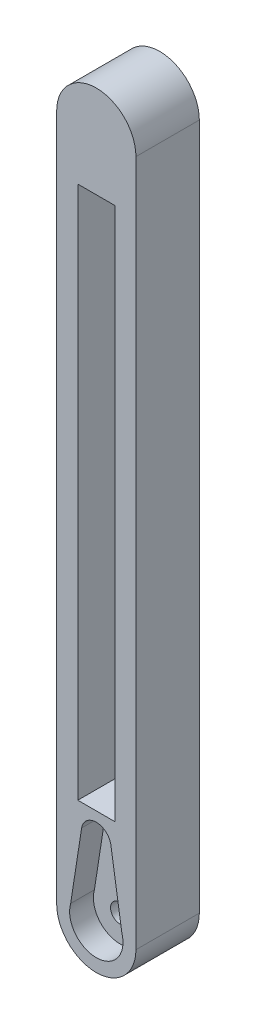
from build123d import *

# Parameters (mm, degrees)
BOSS_EXTRUDE1_DEPTH = 12
SKETCH5_W           = 7
SKETCH5_H           = 112.5
CUT_EXTRUDE3_DEPTH  = 12
SKETCH6_R           = 5.15
CUT_EXTRUDE4_DEPTH  = 2
SKETCH7_W           = 9.454853554
SKETCH7_H           = 12.627623204
BOSS_EXTRUDE2_DEPTH = 12
SKETCH8_R           = 1.8
CUT_EXTRUDE5_DEPTH  = 4.5
SKETCH9_R           = 1.8
CUT_EXTRUDE6_DEPTH  = 13.5
SKETCH10_R          = 2.25
CUT_EXTRUDE7_DEPTH  = 2


with BuildPart() as part:
    # Sketch1 → Boss-Extrude1 (new body)
    with BuildSketch(Plane.XY):
        with BuildLine():
            Line((-5.64516129, 102.580645161), (-5.64516129, -27.419354839))
            ThreePointArc((-5.64516129, -27.419354839), (1.85483871, -34.919354839), (9.35483871, -27.419354839))
            Line((9.35483871, -27.419354839), (9.35483871, 102.580645161))
            ThreePointArc((9.35483871, 102.580645161), (1.85483871, 110.080645161), (-5.64516129, 102.580645161))
        make_face()
    extrude(amount=BOSS_EXTRUDE1_DEPTH)

    # Sketch5 → Cut-Extrude3 (cut)
    with BuildSketch(Plane.XY.offset(12)):
        with Locations((1.85483871, 36.330645161)):
            Rectangle(SKETCH5_W, SKETCH5_H)
    extrude(amount=-CUT_EXTRUDE3_DEPTH, mode=Mode.SUBTRACT)

    # Sketch6 → Cut-Extrude4 (cut)
    with BuildSketch(Plane.ZY.offset(5.64516129)):
        with Locations((6, 78.768969581)):
            Circle(SKETCH6_R)
        with Locations((6, 53.768969581)):
            Circle(SKETCH6_R)
        with Locations((6, 28.768969581)):
            Circle(SKETCH6_R)
    extrude(amount=-CUT_EXTRUDE4_DEPTH, mode=Mode.SUBTRACT)

    # Sketch7 → Boss-Extrude2 (add)
    with BuildSketch(Plane.XY.offset(12)):
        with Locations((2.35113594, -14.728820961)):
            Rectangle(SKETCH7_W, SKETCH7_H)
    extrude(amount=-BOSS_EXTRUDE2_DEPTH)

    # Sketch8 → Cut-Extrude5 (cut)
    with BuildSketch(Plane.XY.offset(12)):
        with BuildLine():
            Line((6.693784724, -25.961716652), (4.61141034, -12.592472516))
            ThreePointArc((4.61141034, -12.592472516), (1.845305929, -10.267914611), (-0.920798482, -12.592472516))
            Line((-0.920798482, -12.592472516), (-2.997287431, -26.006209578))
            ThreePointArc((-2.997287431, -26.006209578), (1.878040737, -32.473023732), (6.693784724, -25.961716652))
        make_face()
        with Locations((1.85483871, -27.419354839)):
            Circle(SKETCH8_R, mode=Mode.SUBTRACT)
    extrude(amount=-CUT_EXTRUDE5_DEPTH, mode=Mode.SUBTRACT)

    # Sketch9 → Cut-Extrude6 (cut)
    with BuildSketch(Plane.XY.offset(12)):
        with Locations((1.85483871, -27.419354839)):
            Circle(SKETCH9_R)
    extrude(amount=-CUT_EXTRUDE6_DEPTH, mode=Mode.SUBTRACT)

    # Sketch10 → Cut-Extrude7 (cut)
    with BuildSketch(Plane(origin=(0, 0, 0), x_dir=(-1, 0, 0), z_dir=(0, 0, -1))):
        with Locations((-1.85483871, -27.419354839)):
            Circle(SKETCH10_R)
    extrude(amount=-CUT_EXTRUDE7_DEPTH, mode=Mode.SUBTRACT)


solid = part.part
